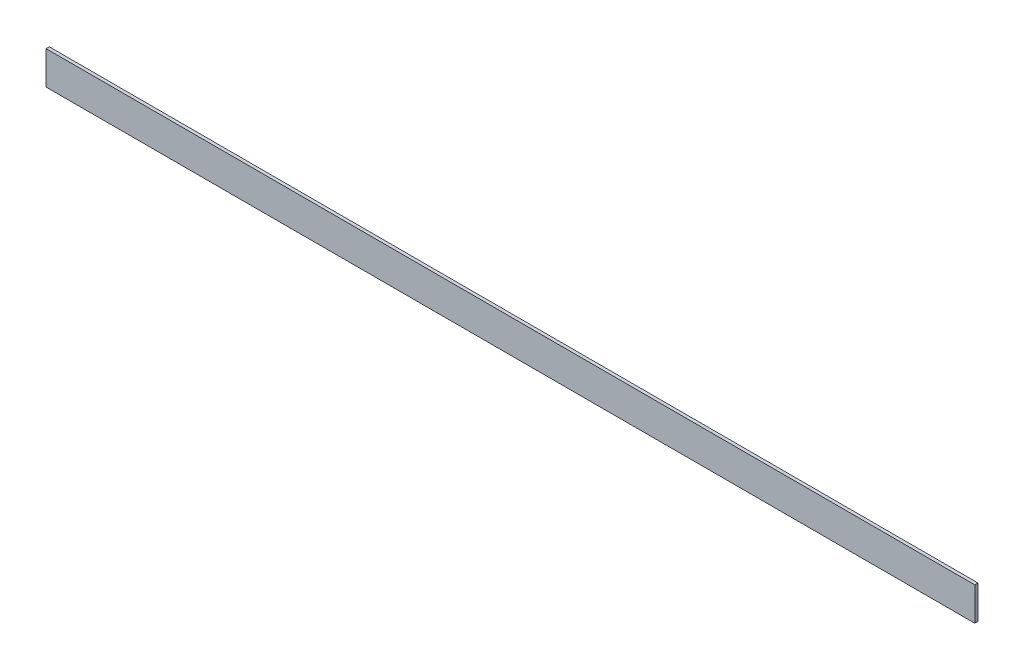
from build123d import *

# Parameters (mm, degrees)
SKETCH1_W           = 920.75
SKETCH1_H           = 33
BOSS_EXTRUDE1_DEPTH = 3.175


with BuildPart() as part:
    # Sketch1 → Boss-Extrude1 (new body)
    with BuildSketch(Plane.XY):
        with Locations((460.375, 16.5)):
            Rectangle(SKETCH1_W, SKETCH1_H)
    extrude(amount=BOSS_EXTRUDE1_DEPTH)


solid = part.part
